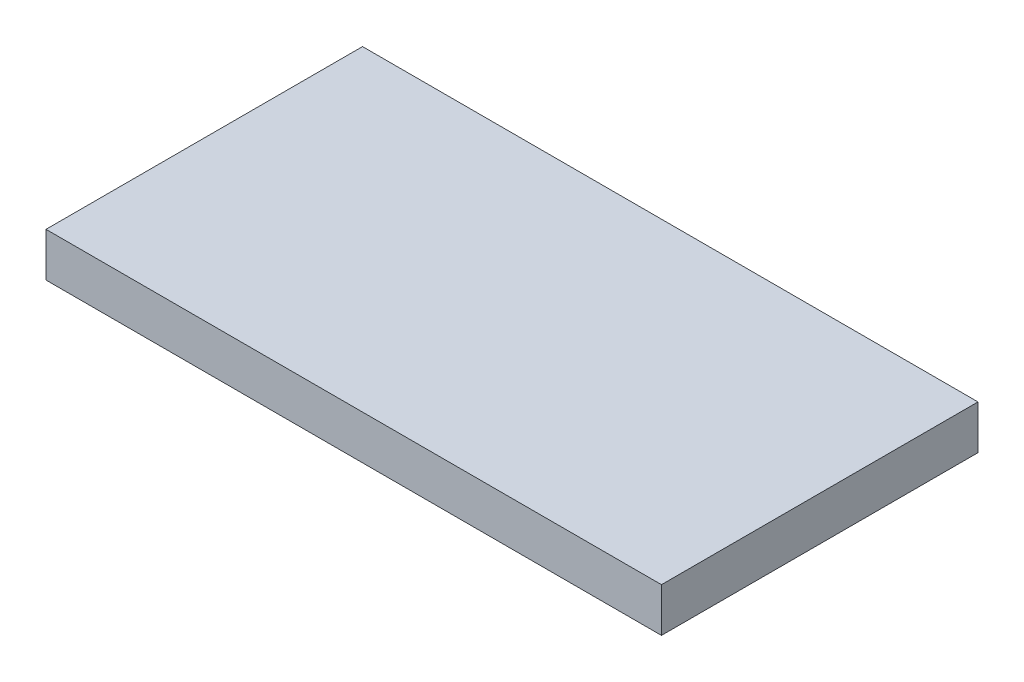
from build123d import *

# Parameters (mm, degrees)
SKETCH1_W           = 44.45
SKETCH1_H           = 22.86
BOSS_EXTRUDE1_DEPTH = 1.5875


with BuildPart() as part:
    # Sketch1 → Boss-Extrude1 (new body, symmetric)
    with BuildSketch(Plane(origin=(0, 0, 0), x_dir=(1, 0, 0), z_dir=(0, 1, 0))):
        Rectangle(SKETCH1_W, SKETCH1_H)
    extrude(amount=BOSS_EXTRUDE1_DEPTH, both=True)


solid = part.part
